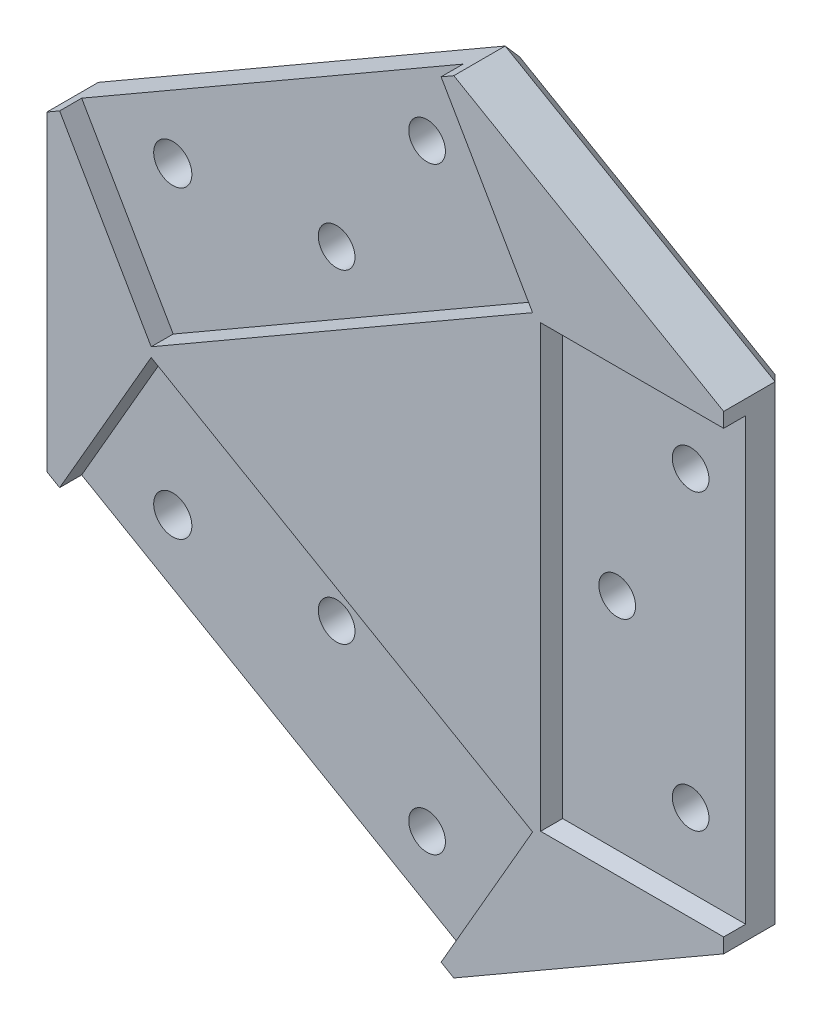
from build123d import *

# Parameters (mm, degrees)
SKETCH1_R           = 2.6
SKETCH1_R_2         = 2.5
BOSS_EXTRUDE2_DEPTH = 9
CHAMFER1_SIZE       = 2
SKETCH3_R           = 2.6
SKETCH3_R_2         = 2.5
SKETCH3_W           = 24.934090133
SKETCH3_H           = 60
CUT_EXTRUDE1_DEPTH  = 3


with BuildPart() as part:
    # Sketch1 → Boss-Extrude2 (new body)
    with BuildSketch(Plane.XY):
        with BuildLine():
            ThreePointArc((2912.593825938, 925.76581843), (2909.393825938, 931.308381015), (2912.593825938, 936.850943599))
            Line((2912.593825938, 936.850943599), (2902.962034909, 953.533695028))
            Line((2902.962034909, 953.533695028), (2901.229984102, 952.533695028))
            Line((2901.229984102, 952.533695028), (2901.229984102, 910.083067001))
            Line((2901.229984102, 910.083067001), (2902.962034909, 909.083067001))
            Line((2902.962034909, 909.083067001), (2912.593825938, 925.76581843))
        make_face()
        with BuildLine():
            Line((2902.962034909, 953.533695028), (2912.593825938, 936.850943599))
            ThreePointArc((2912.593825938, 936.850943599), (2909.393825938, 931.308381015), (2912.593825938, 925.76581843))
            Line((2912.593825938, 925.76581843), (2902.962034909, 909.083067001))
            Line((2902.962034909, 909.083067001), (2954.923559136, 879.083067001))
            Line((2954.923559136, 879.083067001), (2964.555350165, 895.76581843))
            ThreePointArc((2964.555350165, 895.76581843), (2970.955350165, 895.76581843), (2974.155350165, 901.308381015))
            Line((2974.155350165, 901.308381015), (2993.418932222, 901.308381015))
            Line((2993.418932222, 901.308381015), (2993.418932222, 961.308381015))
            Line((2993.418932222, 961.308381015), (2974.155350165, 961.308381015))
            ThreePointArc((2974.155350165, 961.308381015), (2970.955350165, 966.850943599), (2964.555350165, 966.850943599))
            Line((2964.555350165, 966.850943599), (2954.923559136, 983.533695028))
            Line((2954.923559136, 983.533695028), (2902.962034909, 953.533695028))
        make_face()
        with Locations((2915.372288947, 910.57825753)):
            Circle(SKETCH1_R, mode=Mode.SUBTRACT)
        with Locations((2937.692797023, 909.238511568)):
            Circle(SKETCH1_R_2, mode=Mode.SUBTRACT)
        with Locations((2950.013305099, 890.57825753)):
            Circle(SKETCH1_R_2, mode=Mode.SUBTRACT)
        with Locations((2985.918932222, 911.308381015)):
            Circle(SKETCH1_R_2, mode=Mode.SUBTRACT)
        with Locations((2915.372288947, 952.0385045)):
            Circle(SKETCH1_R, mode=Mode.SUBTRACT)
        with BuildLine():
            Line((2920.935519946, 935.119284152), (2961.884164232, 958.760994954))
            ThreePointArc((2961.884164232, 958.760994954), (2964.555350165, 955.76581843), (2968.484842089, 954.950091816))
            Line((2968.484842089, 954.950091816), (2968.484842089, 907.666670213))
            ThreePointArc((2968.484842089, 907.666670213), (2964.555350165, 906.850943599), (2961.884164232, 903.855767076))
            Line((2961.884164232, 903.855767076), (2920.935519946, 927.497477877))
            ThreePointArc((2920.935519946, 927.497477877), (2922.193825938, 931.308381015), (2920.935519946, 935.119284152))
        make_face(mode=Mode.SUBTRACT)
        with Locations((2937.692797023, 953.378250462)):
            Circle(SKETCH1_R_2, mode=Mode.SUBTRACT)
        with Locations((2975.918932222, 931.308381015)):
            Circle(SKETCH1_R_2, mode=Mode.SUBTRACT)
        with Locations((2985.918932222, 951.308381015)):
            Circle(SKETCH1_R_2, mode=Mode.SUBTRACT)
        with Locations((2950.013305099, 972.0385045)):
            Circle(SKETCH1_R_2, mode=Mode.SUBTRACT)
        with BuildLine():
            Line((2956.655609944, 984.533695028), (2954.923559136, 983.533695028))
            Line((2954.923559136, 983.533695028), (2964.555350165, 966.850943599))
            ThreePointArc((2964.555350165, 966.850943599), (2970.955350165, 966.850943599), (2974.155350165, 961.308381015))
            Line((2974.155350165, 961.308381015), (2993.418932222, 961.308381015))
            Line((2993.418932222, 961.308381015), (2993.418932222, 963.308381015))
            Line((2993.418932222, 963.308381015), (2956.655609944, 984.533695028))
        make_face()
        with BuildLine():
            ThreePointArc((2961.884164232, 958.760994954), (2964.555350165, 955.76581843), (2968.484842089, 954.950091816))
            Line((2968.484842089, 954.950091816), (2968.484842089, 907.666670213))
            ThreePointArc((2968.484842089, 907.666670213), (2964.555350165, 906.850943599), (2961.884164232, 903.855767076))
            Line((2961.884164232, 903.855767076), (2920.935519946, 927.497477877))
            ThreePointArc((2920.935519946, 927.497477877), (2922.193825938, 931.308381015), (2920.935519946, 935.119284152))
            Line((2920.935519946, 935.119284152), (2961.884164232, 958.760994954))
        make_face()
        with BuildLine():
            Line((2964.555350165, 895.76581843), (2954.923559136, 879.083067001))
            Line((2954.923559136, 879.083067001), (2956.655609944, 878.083067001))
            Line((2956.655609944, 878.083067001), (2993.418932222, 899.308381015))
            Line((2993.418932222, 899.308381015), (2993.418932222, 901.308381015))
            Line((2993.418932222, 901.308381015), (2974.155350165, 901.308381015))
            ThreePointArc((2974.155350165, 901.308381015), (2970.955350165, 895.76581843), (2964.555350165, 895.76581843))
        make_face()
    extrude(amount=BOSS_EXTRUDE2_DEPTH)

    # Chamfer1
    chamfer1_edges = [part.edges().sort_by_distance(p)[0] for p in [
        (2975.037271083, 888.695724008, 0),
        (2928.942797023, 894.083067001, 0),
        (2901.229984102, 931.308381015, 0),
        (2928.942797023, 968.533695028, 0),
        (2975.037271083, 973.921038021, 0),
        (2993.418932222, 931.308381015, 0),
    ]]
    chamfer(chamfer1_edges, length=CHAMFER1_SIZE)

    # Sketch3 → Cut-Extrude1 (cut)
    with BuildSketch(Plane.XY.offset(9)):
        Polygon((2902.962034909, 909.083067001), (2954.923559136, 879.083067001), (2967.390604203, 900.676622476), (2915.429079976, 930.676622476), align=None)
        with Locations((2915.372288947, 910.57825753)):
            Circle(SKETCH3_R, mode=Mode.SUBTRACT)
        with Locations((2937.692797023, 909.238511568)):
            Circle(SKETCH3_R_2, mode=Mode.SUBTRACT)
        with Locations((2950.013305099, 890.57825753)):
            Circle(SKETCH3_R_2, mode=Mode.SUBTRACT)
        Polygon((2967.390604203, 961.940139553), (2954.923559136, 983.533695028), (2902.962034909, 953.533695028), (2915.429079976, 931.940139553), align=None)
        with Locations((2915.372288947, 952.0385045)):
            Circle(SKETCH3_R, mode=Mode.SUBTRACT)
        with Locations((2937.692797023, 953.378250462)):
            Circle(SKETCH3_R_2, mode=Mode.SUBTRACT)
        with Locations((2950.013305099, 972.0385045)):
            Circle(SKETCH3_R_2, mode=Mode.SUBTRACT)
        with Locations((2980.951887156, 931.308381015)):
            Rectangle(SKETCH3_W, SKETCH3_H)
        with Locations((2985.918932222, 911.308381015)):
            Circle(SKETCH3_R_2, mode=Mode.SUBTRACT)
        with Locations((2975.918932222, 931.308381015)):
            Circle(SKETCH3_R_2, mode=Mode.SUBTRACT)
        with Locations((2985.918932222, 951.308381015)):
            Circle(SKETCH3_R_2, mode=Mode.SUBTRACT)
    extrude(amount=-CUT_EXTRUDE1_DEPTH, mode=Mode.SUBTRACT)


solid = part.part
